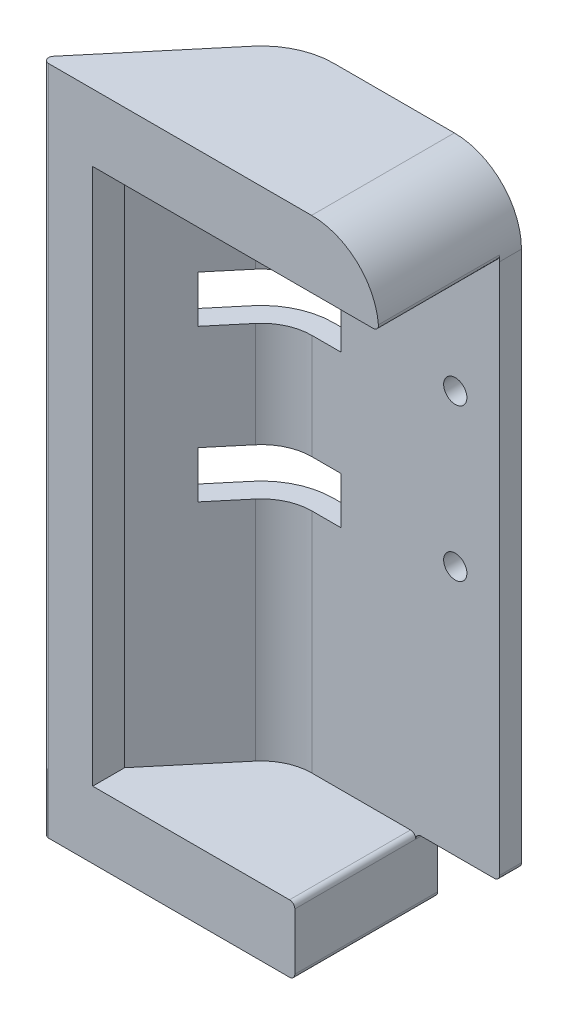
from build123d import *

# Parameters (mm, degrees)
BOSS_EXTRUDE1_DEPTH     = 127
SKETCH2_R               = 2.049999964
SKETCH2_W               = 19.05
SKETCH2_H               = 8.89
CUT_EXTRUDE1_DEPTH      = 25.48749992
FILLET1_R               = 12.7
BOSS_EXTRUDE2_REACH     = 18.672
SKETCH4_W               = 1.891908828
SKETCH4_H               = 8.89
BOSS_EXTRUDE3_DEPTH     = 12.7
SKETCH6_W               = 15.875
SKETCH6_H               = 12.7
CUT_EXTRUDE2_DEPTH      = 25.48749992
BOSS_EXTRUDE4_DEPTH     = 127
SKETCH8_R               = 2.200000045
SKETCH8_W               = 17.833904447
SKETCH8_H               = 8.89
SKETCH8_W_2             = 15.875
SKETCH8_H_2             = 12.7
CUT_EXTRUDE3_DEPTH      = 23.89999992
CUT_EXTRUDE3_DEPTH_BACK = 5.1275
SKETCH9_W               = 4.918962954
SKETCH9_H               = 8.89
CUT_EXTRUDE4_DEPTH      = 22.500442069
FILLET2_R               = 1
FILLET3_R               = 1
BOSS_EXTRUDE5_DEPTH     = 114.3
BOSS_EXTRUDE6_DEPTH     = 12.7
CUT_EXTRUDE5_DEPTH      = 23.89999992
FILLET4_R               = 1


with BuildPart() as part:
    # Sketch1 → Boss-Extrude1 (new body)
    with BuildSketch(Plane(origin=(0, 0, 0), x_dir=(1, 0, 0), z_dir=(0, 1, 0))):
        with BuildLine():
            Line((0, 0), (-35.56, 0))
            ThreePointArc((-35.56, 0), (-39.585438943, -0.892418328), (-42.856573321, -3.402448018))
            Line((-42.856573321, -3.402448018), (-59.216961931, -22.89999992))
            Line((-59.216961931, -22.89999992), (-60.433057484, -21.87957459))
            Line((-60.433057484, -21.87957459), (-44.072668874, -2.382022687))
            ThreePointArc((-44.072668874, -2.382022687), (-40.256345434, 0.546345283), (-35.56, 1.5875))
            Line((-35.56, 1.5875), (0, 1.5875))
            Line((0, 1.5875), (0, 0))
        make_face()
    extrude(amount=BOSS_EXTRUDE1_DEPTH)

    # Sketch2 → Cut-Extrude1 (cut, through all)
    with BuildSketch(Plane(origin=(0, 0, -1.5875), x_dir=(-1, 0, 0), z_dir=(0, 0, -1))):
        with Locations((8.399999964, 88.9)):
            Circle(SKETCH2_R)
        with Locations((8.399999964, 60.116067728)):
            Circle(SKETCH2_R)
        with Locations((39.514999964, 88.9)):
            Rectangle(SKETCH2_W, SKETCH2_H)
        with Locations((39.514999964, 60.116067728)):
            Rectangle(SKETCH2_W, SKETCH2_H)
    extrude(amount=-CUT_EXTRUDE1_DEPTH, mode=Mode.SUBTRACT)

    # Fillet1
    fillet1_edges = [part.edges().sort_by_distance(p)[0] for p in [
        (0, 0, -0.79375),
        (-59.825009707, 127, 22.389787255),
        (0, 127, -0.79375),
        (-59.825009707, 0, 22.389787255),
    ]]
    fillet(fillet1_edges, radius=FILLET1_R)

    # Boss-Extrude2: up to this face of the body (flat: up to its plane)
    boss_extrude2_end = Plane(part.part.faces().sort_by_distance((-49.039999964, 88.9, 9.536713147))[0])
    # Sketch4 → Boss-Extrude2 (add, up to the picked face)
    with BuildSketch(Plane(origin=(-23.473890996, 0, -19.696933277), x_dir=(0.64278761, 0, -0.766044443), z_dir=(0.766044443, 0, 0.64278761)), mode=Mode.PRIVATE) as boss_extrude2_sk1:
        with Locations((-38.827850468, 88.9)):
            Rectangle(SKETCH4_W, SKETCH4_H)
    boss_extrude2_tool1 = split(extrude(boss_extrude2_sk1.sketch, amount=-BOSS_EXTRUDE2_REACH, mode=Mode.PRIVATE), bisect_by=boss_extrude2_end, keep=Keep.BOTH, mode=Mode.PRIVATE)
    add(boss_extrude2_tool1.solids().sort_by_distance((-48.431952, 88.9, 10.046926))[0])
    # Sketch4 → Boss-Extrude2 (add, up to the picked face)
    with BuildSketch(Plane(origin=(-23.473890996, 0, -19.696933277), x_dir=(0.64278761, 0, -0.766044443), z_dir=(0.766044443, 0, 0.64278761)), mode=Mode.PRIVATE) as boss_extrude2_sk2:
        with Locations((-38.827850468, 60.116067728)):
            Rectangle(SKETCH4_W, SKETCH4_H)
    boss_extrude2_tool2 = split(extrude(boss_extrude2_sk2.sketch, amount=-BOSS_EXTRUDE2_REACH, mode=Mode.PRIVATE), bisect_by=boss_extrude2_end, keep=Keep.BOTH, mode=Mode.PRIVATE)
    add(boss_extrude2_tool2.solids().sort_by_distance((-48.431952, 60.116068, 10.046926))[0])

    # Sketch5 → Boss-Extrude3 (add)
    with BuildSketch(Plane.XZ):
        with BuildLine():
            Line((-44.072668874, 2.382022687), (-60.433057484, 21.87957459))
            Line((-60.433057484, 21.87957459), (-59.216961931, 22.89999992))
            Line((-59.216961931, 22.89999992), (0, 22.89999992))
            Line((0, 22.89999992), (0, -1.5875))
            Line((0, -1.5875), (-35.56, -1.5875))
            ThreePointArc((-35.56, -1.5875), (-40.256345434, -0.546345283), (-44.072668874, 2.382022687))
        make_face()
    extrude(amount=-BOSS_EXTRUDE3_DEPTH)

    # Sketch6 → Cut-Extrude2 (cut, through all)
    with BuildSketch(Plane(origin=(0, 0, -1.5875), x_dir=(-1, 0, 0), z_dir=(0, 0, -1))):
        with Locations((7.9375, 6.35)):
            Rectangle(SKETCH6_W, SKETCH6_H)
    extrude(amount=-CUT_EXTRUDE2_DEPTH, mode=Mode.SUBTRACT)

    # Sketch7 → Boss-Extrude4 (add)
    with BuildSketch(Plane.XZ):
        with BuildLine():
            Line((-59.216961931, 22.89999992), (-64.605030517, 22.89999992))
            Line((-64.605030517, 22.89999992), (-46.01842176, 0.749342159))
            ThreePointArc((-46.01842176, 0.749342159), (-41.329795818, -2.848367063), (-35.56, -4.1275))
            Line((-35.56, -4.1275), (0, -4.1275))
            Line((0, -4.1275), (0, -1.5875))
            Line((0, -1.5875), (-15.875, -1.5875))
            Line((-15.875, -1.5875), (-35.56, -1.5875))
            ThreePointArc((-35.56, -1.5875), (-40.256345434, -0.546345283), (-44.072668874, 2.382022687))
            Line((-44.072668874, 2.382022687), (-52.269654841, 12.150810162))
            Line((-52.269654841, 12.150810162), (-51.053559288, 13.171235492))
            Line((-51.053559288, 13.171235492), (-59.216961931, 22.89999992))
        make_face()
    extrude(amount=-BOSS_EXTRUDE4_DEPTH)

    # Sketch8 → Cut-Extrude3 (cut, two sides)
    with BuildSketch(Plane.XY) as cut_extrude3_sk:
        with Locations((-8.399999964, 88.9)):
            Circle(SKETCH8_R)
        with Locations((-8.399999964, 60.116067728)):
            Circle(SKETCH8_R)
        with BuildLine():
            Line((-12.7, 127), (0, 127))
            Line((0, 127), (0, 114.3))
            ThreePointArc((0, 114.3), (-3.719743879, 123.280256121), (-12.7, 127))
        make_face()
        with Locations((-38.906952188, 88.9)):
            Rectangle(SKETCH8_W, SKETCH8_H)
        with Locations((-38.906952188, 60.116067728)):
            Rectangle(SKETCH8_W, SKETCH8_H)
        with Locations((-7.9375, 6.35)):
            Rectangle(SKETCH8_W_2, SKETCH8_H_2)
    extrude(amount=CUT_EXTRUDE3_DEPTH, mode=Mode.SUBTRACT)
    extrude(cut_extrude3_sk.sketch, amount=-CUT_EXTRUDE3_DEPTH_BACK, mode=Mode.SUBTRACT)

    # Sketch9 → Cut-Extrude4 (cut, through all)
    with BuildSketch(Plane(origin=(-23.473890996, 0, -19.696933277), x_dir=(0.64278761, 0, -0.766044443), z_dir=(0.766044443, 0, 0.64278761))):
        with Locations((-35.422414577, 88.9)):
            Rectangle(SKETCH9_W, SKETCH9_H)
        with Locations((-35.422414577, 60.116067728)):
            Rectangle(SKETCH9_W, SKETCH9_H)
    extrude(amount=-CUT_EXTRUDE4_DEPTH, mode=Mode.SUBTRACT)

    # Fillet2
    fillet2_edges = [part.edges().sort_by_distance(p)[0] for p in [
        (0, 12.7, -2.06375),
        (-15.875, 12.7, 11.44999996),
        (-15.875, 0, 9.38624996),
        (-64.605030517, 63.5, 22.89999992),
    ]]
    fillet(fillet2_edges, radius=FILLET2_R)

    # Fillet3
    fillet3_edges = [part.edges().sort_by_distance(p)[0] for p in [
        (-15.875, 12.7, -2.06375),
    ]]
    fillet(fillet3_edges, radius=FILLET3_R)

    # Sketch10 → Boss-Extrude5 (add)
    with BuildSketch(Plane(origin=(0, 12.7, 0), x_dir=(1, 0, 0), z_dir=(0, 1, 0))):
        Polygon((-59.216961931, -22.89999992), (-54.136961931, -22.89999992), (-54.136961931, -16.84589167), align=None)
    extrude(amount=BOSS_EXTRUDE5_DEPTH)

    # Sketch11 → Boss-Extrude6 (add)
    with BuildSketch(Plane(origin=(0, 114.3, 0), x_dir=(1, 0, 0), z_dir=(0, 1, 0))):
        with BuildLine():
            Line((-54.136961931, -22.89999992), (-54.136961931, -16.84589167))
            Line((-54.136961931, -16.84589167), (-42.856573321, -3.402448018))
            ThreePointArc((-42.856573321, -3.402448018), (-39.585438943, -0.892418328), (-35.56, 0))
            Line((-35.56, 0), (0, 0))
            Line((0, 0), (0, -22.89999992))
            Line((0, -22.89999992), (-54.136961931, -22.89999992))
        make_face()
    extrude(amount=BOSS_EXTRUDE6_DEPTH)

    # Sketch12 → Cut-Extrude5 (cut, through all)
    with BuildSketch(Plane(origin=(0, 0, 0), x_dir=(-1, 0, 0), z_dir=(0, 0, -1))):
        with BuildLine():
            Line((12.7, 127), (0, 127))
            Line((0, 127), (0, 114.3))
            ThreePointArc((0, 114.3), (3.719743879, 123.280256121), (12.7, 127))
        make_face()
    extrude(amount=-CUT_EXTRUDE5_DEPTH, mode=Mode.SUBTRACT)

    # Fillet4
    fillet4_edges = [part.edges().sort_by_distance(p)[0] for p in [
        (0, 114.3, 11.44999996),
    ]]
    fillet(fillet4_edges, radius=FILLET4_R)


solid = part.part
